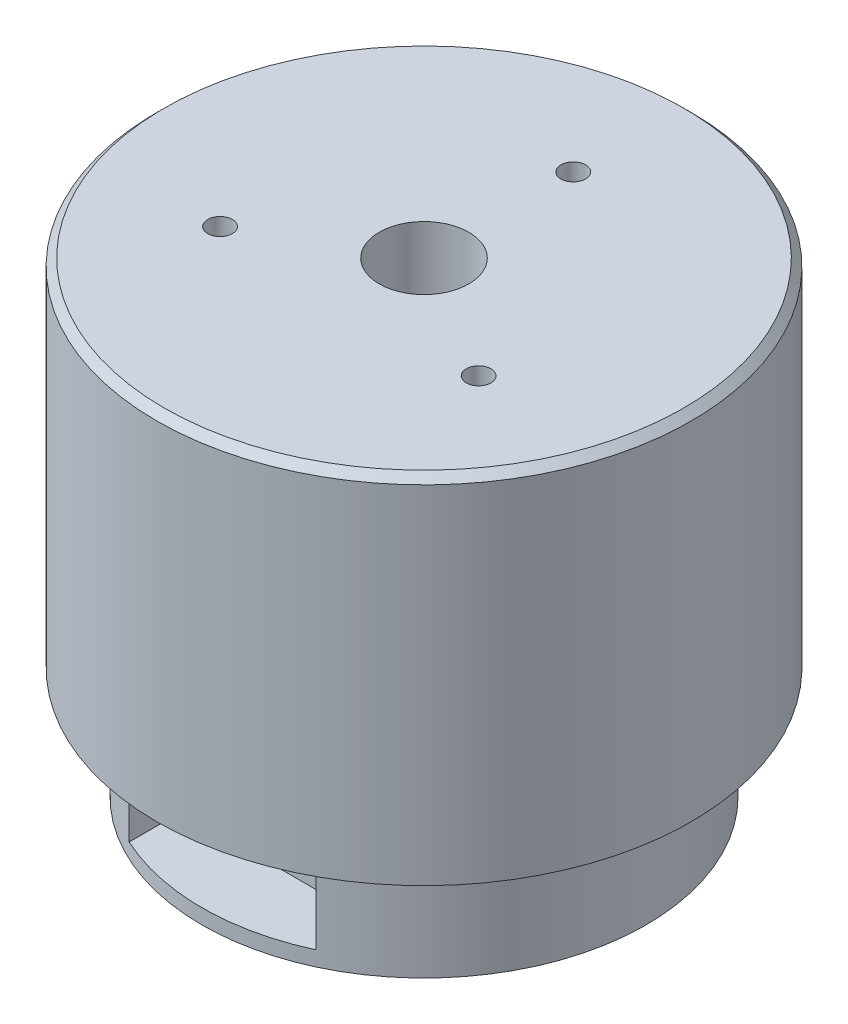
from build123d import *

# Parameters (mm, degrees)
SKETCH1_R             = 29.75
BOSS_EXTRUDE1_DEPTH   = 16
SKETCH2_R             = 35.8
BOSS_EXTRUDE2_DEPTH   = 47.5
M4_TAPPED_HOLE1_D     = 3.3
M4_TAPPED_HOLE1_DEPTH = 6
M4_TAPPED_HOLE1_TIP   = 0.991420021
SKETCH6_R             = 6
CUT_EXTRUDE1_DEPTH    = 20
CHAMFER1_SIZE         = 1
CHAMFER2_SIZE         = 1
CHAMFER2_SIZE2        = 3.732050808
CUT_EXTRUDE2_START    = 20
SKETCH7_W             = 25
SKETCH7_H             = 13
CUT_EXTRUDE2_DEPTH    = 20


with BuildPart() as part:
    # Sketch1 → Boss-Extrude1 (new body)
    with BuildSketch(Plane(origin=(0, 0, 0), x_dir=(1, 0, 0), z_dir=(0, 1, 0))):
        Circle(SKETCH1_R)
    extrude(amount=BOSS_EXTRUDE1_DEPTH)

    # Sketch2 → Boss-Extrude2 (add)
    with BuildSketch(Plane(origin=(0, 16, 0), x_dir=(1, 0, 0), z_dir=(0, 1, 0))):
        Circle(SKETCH2_R)
    extrude(amount=BOSS_EXTRUDE2_DEPTH)

    # M4 Tapped Hole1
    with Locations(Plane(origin=(0, 63.5, 0), x_dir=(1, 0, 0), z_dir=(0, 1, 0))):
        with Locations((0, 20), (17.320508076, -10), (-17.320508076, -10)):
            Hole(M4_TAPPED_HOLE1_D / 2, depth=M4_TAPPED_HOLE1_DEPTH)
            with Locations((0, 0, -(M4_TAPPED_HOLE1_DEPTH + M4_TAPPED_HOLE1_TIP / 2))):  # 118° drill point
                Cone(0, M4_TAPPED_HOLE1_D / 2, M4_TAPPED_HOLE1_TIP, mode=Mode.SUBTRACT)

    # Sketch6 → Cut-Extrude1 (cut)
    with BuildSketch(Plane(origin=(0, 63.5, 0), x_dir=(1, 0, 0), z_dir=(0, 1, 0))):
        Circle(SKETCH6_R)
    extrude(amount=-CUT_EXTRUDE1_DEPTH, mode=Mode.SUBTRACT)

    # Chamfer1
    chamfer1_edges = [part.edges().sort_by_distance(p)[0] for p in [
        (-35.8, 63.5, 0),
    ]]
    chamfer(chamfer1_edges, length=CHAMFER1_SIZE)

    # Chamfer2
    chamfer2_edges = [part.edges().sort_by_distance(p)[0] for p in [
        (-29.75, 0, 0),
    ]]
    chamfer2_side = [part.faces().sort_by_distance(p)[0] for p in [
        (-29.75, 8, 0),
    ]]
    chamfer(chamfer2_edges, length=CHAMFER2_SIZE, length2=CHAMFER2_SIZE2, reference=chamfer2_side[0])

    # Sketch7 → Cut-Extrude2 (cut)
    with BuildSketch(Plane.XY.offset(CUT_EXTRUDE2_START)):
        with Locations((0, 9.5)):
            Rectangle(SKETCH7_W, SKETCH7_H)
    extrude(amount=CUT_EXTRUDE2_DEPTH, mode=Mode.SUBTRACT)


solid = part.part
